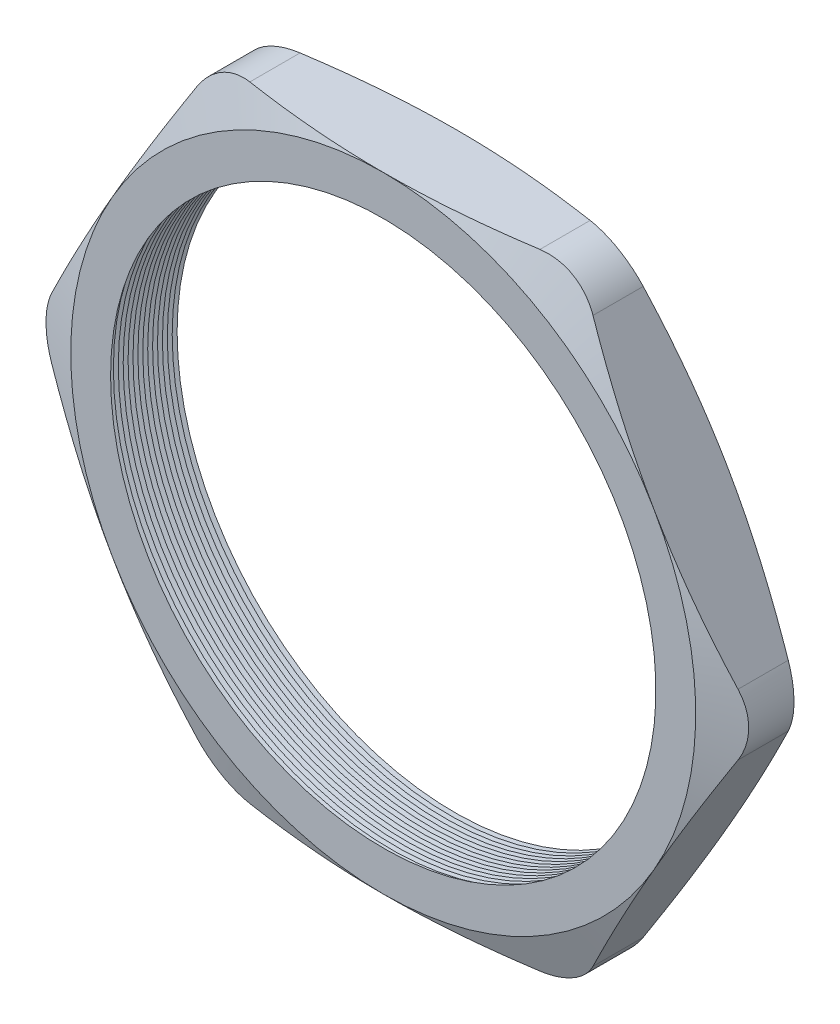
from build123d import *

# Parameters (mm, degrees)
SKETCH1_R          = 11.303
EXTRUDE1_DEPTH     = 3.048
FILLET1_R          = 2.54
SKETCH2_OUTSIDE_W  = 61.194
SKETCH2_OUTSIDE_H  = 57.972
SKETCH2_OUTSIDE_R  = 12.954
CUT_EXTRUDE1_DEPTH = 4.048
CUT_EXTRUDE1_DRAFT = -70
SKETCH3_OUTSIDE_W  = 61.194
SKETCH3_OUTSIDE_H  = 57.972
SKETCH3_OUTSIDE_R  = 12.954
CUT_EXTRUDE2_DEPTH = 4.0480001
CUT_EXTRUDE2_DRAFT = -70
LPATTERN1_COUNT    = 15
LPATTERN1_PITCH    = 0.2032


with BuildPart() as part:
    # Sketch1 → Extrude1 (new body)
    with BuildSketch(Plane.XY):
        Polygon((-14.957990774, 0), (-7.478995387, -12.954), (7.478995387, -12.954), (14.957990774, 0), (7.478995387, 12.954), (-7.478995387, 12.954), align=None)
        Circle(SKETCH1_R, mode=Mode.SUBTRACT)
    extrude(amount=EXTRUDE1_DEPTH)

    # Fillet1
    fillet1_edges = [part.edges().sort_by_distance(p)[0] for p in [
        (14.957990774, 0, 1.524),
        (7.478995387, -12.954, 1.524),
        (-7.478995387, -12.954, 1.524),
        (-14.957990774, 0, 1.524),
        (-7.478995387, 12.954, 1.524),
        (7.478995387, 12.954, 1.524),
    ]]
    fillet(fillet1_edges, radius=FILLET1_R)


with BuildPart() as cut_extrude1_tool:
    # Sketch2 outside → Cut-Extrude1 (with draft: the straight prism first)
    with BuildSketch(Plane.XY.offset(3.048)):
        Rectangle(SKETCH2_OUTSIDE_W, SKETCH2_OUTSIDE_H)
        Circle(SKETCH2_OUTSIDE_R, mode=Mode.SUBTRACT)
    extrude(amount=-CUT_EXTRUDE1_DEPTH)
    # Cut-Extrude1: the draft: its side faces are tilted about the plane it starts from
    cut_extrude1_sides = [cut_extrude1_tool.faces().sort_by_distance(p)[0] for p in [
        (0, -28.986, 1.024),
        (30.597, 0, 1.024),
        (0, 28.986, 1.024),
        (-30.597, 0, 1.024),
        (-12.954, 0, 1.024),
    ]]
    draft(cut_extrude1_sides, Plane.XY.offset(3.048), CUT_EXTRUDE1_DRAFT)


with BuildPart() as part_1:
    add(part.part)

    # Cut-Extrude1: cut by cut_extrude1_tool
    add(cut_extrude1_tool.part, mode=Mode.SUBTRACT)


with BuildPart() as cut_extrude2_tool:
    # Sketch3 outside → Cut-Extrude2 (with draft: the straight prism first)
    with BuildSketch(Plane(origin=(0, 0, 0), x_dir=(-1, 0, 0), z_dir=(0, 0, -1))):
        Rectangle(SKETCH3_OUTSIDE_W, SKETCH3_OUTSIDE_H)
        Circle(SKETCH3_OUTSIDE_R, mode=Mode.SUBTRACT)
    extrude(amount=-CUT_EXTRUDE2_DEPTH)
    # Cut-Extrude2: the draft: its side faces are tilted about the plane it starts from
    cut_extrude2_sides = [cut_extrude2_tool.faces().sort_by_distance(p)[0] for p in [
        (0, -28.986, 2.02400005),
        (-30.597, 0, 2.02400005),
        (0, 28.986, 2.02400005),
        (30.597, 0, 2.02400005),
        (12.954, 0, 2.02400005),
    ]]
    draft(cut_extrude2_sides, Plane(origin=(0, 0, 0), x_dir=(-1, 0, 0), z_dir=(0, 0, -1)), CUT_EXTRUDE2_DRAFT)


with BuildPart() as part_2:
    add(part_1.part)

    # Cut-Extrude2: cut by cut_extrude2_tool
    add(cut_extrude2_tool.part, mode=Mode.SUBTRACT)

    # Sketch4 → Cut-Revolve1 (revolve, cut)
    with BuildSketch(Plane(origin=(0, 0, 0), x_dir=(1, 0, 0), z_dir=(0, 1, 0))):
        Polygon((-11.303, -3.048), (-11.303, -2.608059095), (-11.684, -2.828029547), align=None)
    cut_revolve1 = revolve(axis=Axis((0, 0, 3.048), (0, 0, -1)), mode=Mode.SUBTRACT)

    # LPattern1: Cut-Revolve1 ×15
    with Locations(*[(0, 0, -i * LPATTERN1_PITCH) for i in range(1, LPATTERN1_COUNT)]):
        add(cut_revolve1, mode=Mode.SUBTRACT)


solid = part_2.part
